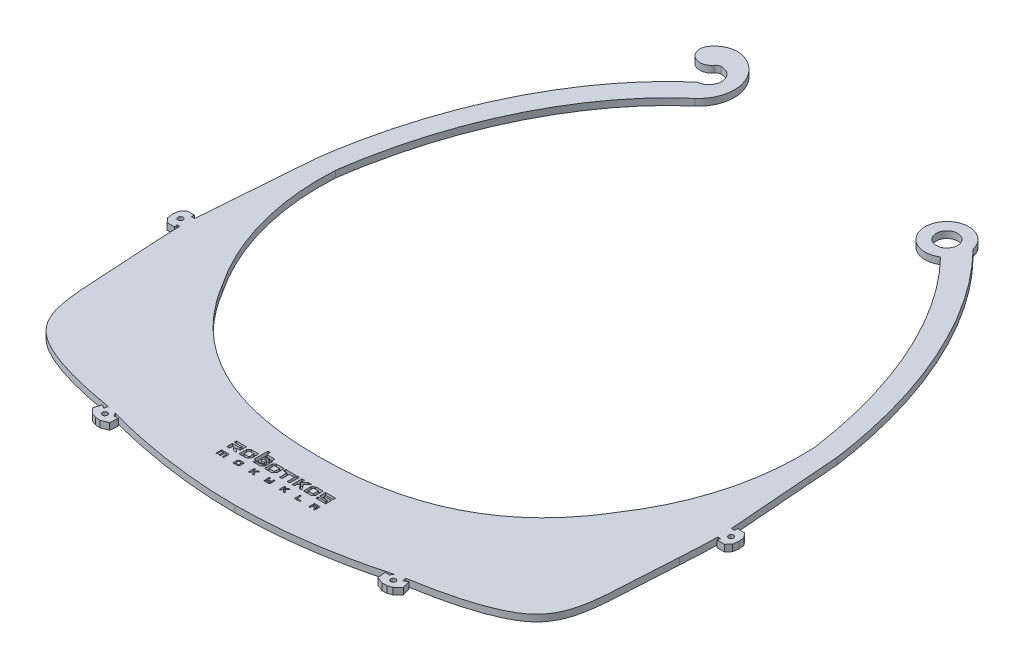
from build123d import *

# Parameters (mm, degrees)
SKETCH2_R           = 0.75
SKETCH2_R_2         = 3.169794379
BOSS_EXTRUDE2_DEPTH = 2
CUT_EXTRUDE1_DEPTH  = 1


with BuildPart() as part:
    # Sketch2 → Boss-Extrude2 (new body)
    with BuildSketch(Plane(origin=(0, 0, 0), x_dir=(1, 0, 0), z_dir=(0, 1, 0))):
        with BuildLine():
            Line((-145.774014845, 4699.790846236), (-145.679424713, 4700.667060475))
            Line((-145.679424713, 4700.667060475), (-147.918372484, 4700.606196913))
            Line((-147.918372484, 4700.606196913), (-149.027988208, 4699.255761252))
            Line((-149.027988208, 4699.255761252), (-149.222790895, 4697.597182293))
            Line((-149.222790895, 4697.597182293), (-148.98298998, 4695.944509376))
            Line((-148.98298998, 4695.944509376), (-147.837087324, 4694.624725063))
            Line((-147.837087324, 4694.624725063), (-145.597312449, 4694.624725063))
            Line((-145.597312449, 4694.624725063), (-145.773758332, 4695.519138342))
            Line((-145.773758332, 4695.519138342), (-144.93974364, 4695.519138342))
            add(Edge.make_bspline(
                [(-144.46397827, 4684.514714632), (-144.606093665, 4687.588466409), (-144.901928293, 4691.324791696), (-144.93974364, 4695.519138342)],
                knots=[0.004734857, 0.004734857, 0.004734857, 0.004734857, 0.035161677, 0.035161677, 0.035161677, 0.035161677], degree=3))
            add(Edge.make_bspline(
                [(-108.903375625, 4638.035656948), (-118.821969125, 4639.685871765), (-132.493488743, 4643.060373116), (-144.218775593, 4654.394416396), (-143.099113193, 4666.334603474), (-144.46397827, 4684.514714632)],
                knots=[0.018902136, 0.018902136, 0.018902136, 0.018902136, 0.394121885, 0.490994555, 0.987628845, 0.987628845, 0.987628845, 0.987628845], degree=3))
            Line((-108.903375625, 4638.035656948), (-109.111012106, 4636.936921529))
            Line((-109.111012106, 4636.936921529), (-110.228421491, 4637.612566847))
            Line((-110.228421491, 4637.612566847), (-110.904437831, 4635.297018365))
            Line((-110.904437831, 4635.297018365), (-109.31209767, 4633.795971308))
            Line((-109.31209767, 4633.795971308), (-107.959504664, 4633.340434244))
            Line((-107.959504664, 4633.340434244), (-106.534299374, 4633.264199495))
            Line((-106.534299374, 4633.264199495), (-104.500152189, 4634.07100473))
            Line((-104.500152189, 4634.07100473), (-104.273152305, 4636.472511323))
            Line((-104.273152305, 4636.472511323), (-105.57754023, 4636.472511323))
            Line((-105.57754023, 4636.472511323), (-106.108269156, 4637.355076027))
            add(Edge.make_bspline(
                [(-64.303390576, 4631.426207785), (-78.229594734, 4631.453371402), (-92.531802759, 4633.559092847), (-106.108269156, 4637.355076027)],
                knots=[0.500293183, 0.500293183, 0.500293183, 0.500293183, 0.981944699, 0.981944699, 0.981944699, 0.981944699], degree=3))
            add(Edge.make_bspline(
                [(-64.303390576, 4631.426207785), (-50.377186419, 4631.453371402), (-36.074978393, 4633.559092847), (-22.498511996, 4637.355076027)],
                knots=[0.500293183, 0.500293183, 0.500293183, 0.500293183, 0.981944699, 0.981944699, 0.981944699, 0.981944699], degree=3))
            Line((-22.498511996, 4637.355076027), (-23.029240922, 4636.472511323))
            Line((-23.029240922, 4636.472511323), (-24.333628848, 4636.472511323))
            Line((-24.333628848, 4636.472511323), (-24.106628964, 4634.07100473))
            Line((-24.106628964, 4634.07100473), (-22.072481779, 4633.264199495))
            Line((-22.072481779, 4633.264199495), (-20.647276489, 4633.340434244))
            Line((-20.647276489, 4633.340434244), (-19.294683483, 4633.795971308))
            Line((-19.294683483, 4633.795971308), (-17.702343322, 4635.297018365))
            Line((-17.702343322, 4635.297018365), (-18.378359662, 4637.612566847))
            Line((-18.378359662, 4637.612566847), (-19.495769046, 4636.936921529))
            Line((-19.495769046, 4636.936921529), (-19.703405528, 4638.035656948))
            add(Edge.make_bspline(
                [(-19.703405528, 4638.035656948), (-9.784812028, 4639.685871765), (3.88670759, 4643.060373116), (15.611994441, 4654.394416396), (14.49233204, 4666.334603474), (15.857197118, 4684.514714632)],
                knots=[0.018902136, 0.018902136, 0.018902136, 0.018902136, 0.394121885, 0.490994555, 0.987628845, 0.987628845, 0.987628845, 0.987628845], degree=3))
            add(Edge.make_bspline(
                [(15.857197118, 4684.514714632), (15.999312513, 4687.588466409), (16.29514714, 4691.324791696), (16.332962487, 4695.519138342)],
                knots=[0.004734857, 0.004734857, 0.004734857, 0.004734857, 0.035161677, 0.035161677, 0.035161677, 0.035161677], degree=3))
            Line((16.332962487, 4695.519138342), (17.166977179, 4695.519138342))
            Line((17.166977179, 4695.519138342), (16.990531296, 4694.624725063))
            Line((16.990531296, 4694.624725063), (19.230306172, 4694.624725063))
            Line((19.230306172, 4694.624725063), (20.376208827, 4695.944509376))
            Line((20.376208827, 4695.944509376), (20.616009742, 4697.597182293))
            Line((20.616009742, 4697.597182293), (20.421207056, 4699.255761252))
            Line((20.421207056, 4699.255761252), (19.311591332, 4700.606196913))
            Line((19.311591332, 4700.606196913), (17.072643561, 4700.667060475))
            Line((17.072643561, 4700.667060475), (17.167233693, 4699.790846236))
            Line((17.167233693, 4699.790846236), (16.143581312, 4699.790846236))
            Line((16.143581312, 4699.790846236), (13.505704616, 4734.046734393))
            add(Edge.make_bspline(
                [(-20.140377949, 4808.505435192), (-19.339215101, 4807.69878822), (-16.169205429, 4804.385156989), (-10.959428961, 4798.073334595), (-4.937431717, 4789.049110006), (0.359464838, 4779.225886251), (4.896611241, 4768.706679247), (8.641256086, 4757.60156043), (11.078840538, 4747.950225277), (12.60715411, 4740.056303981), (13.230863748, 4736.050334581), (13.505704616, 4734.046734393)],
                knots=[-2.547822097, -2.547822097, -2.547822097, -2.547822097, -2.512682102, -2.406957035, -2.301231967, -2.1955069, -2.089781833, -1.984056766, -1.878331699, -1.825469165, -1.772606631, -1.772606631, -1.772606631, -1.772606631], degree=3))
            ThreePointArc((-20.140377949, 4808.505435192), (-32.664266502, 4809.623514522), (-22.989188291, 4801.592901377))
            add(Edge.make_bspline(
                [(7.531205359, 4733.448618243), (1.49518461, 4776.711269913), (-22.989188291, 4801.592901377)],
                knots=[1.775964024, 1.775964024, 1.775964024, 2.543499924, 2.543499924, 2.543499924], degree=2, weights=[1, 0.927260437, 1]))
            ThreePointArc((7.531205359, 4733.448618243), (4.986516441, 4708.998918893), (-5.29304341, 4686.669702846))
            add(Edge.make_bspline(
                [(-64.303390576, 4656.572608608), (-23.423446833, 4656.293379669), (-5.29304341, 4686.669702846)],
                knots=[0, 0, 0, 1, 1, 1], degree=2))
            add(Edge.make_bspline(
                [(-64.303390576, 4656.572608608), (-105.18333432, 4656.293379669), (-123.313737743, 4686.669702846)],
                knots=[0, 0, 0, 1, 1, 1], degree=2))
            ThreePointArc((-123.313737743, 4686.669702846), (-133.593297594, 4708.998918893), (-136.137986511, 4733.448618243))
            add(Edge.make_bspline(
                [(-100.963860647, 4805.950790548), (-129.440493439, 4781.452315035), (-136.137986511, 4733.448618243)],
                knots=[3.66477814, 3.66477814, 3.66477814, 4.507221283, 4.507221283, 4.507221283], degree=2, weights=[1, 0.912590151, 1]))
            ThreePointArc((-100.963860647, 4805.950790548), (-97.422627424, 4815.929347659), (-104.224712723, 4824.043752771))
            ThreePointArc((-104.224712723, 4824.043752771), (-108.705347231, 4824.182862669), (-112.368006092, 4821.59822203))
            ThreePointArc((-112.368006092, 4821.59822203), (-111.611928523, 4816.659274376), (-106.672980869, 4817.415351945))
            ThreePointArc((-106.672980869, 4817.415351945), (-106.103107375, 4817.914471202), (-105.375761358, 4818.126234287))
            ThreePointArc((-105.375761358, 4818.126234287), (-101.312817548, 4814.562168737), (-104.876883098, 4810.499224928))
            add(Edge.make_bspline(
                [(-104.876883098, 4810.499224928), (-106.096560831, 4809.44993496), (-108.458644854, 4807.290890126), (-113.03760026, 4802.595468236), (-118.390037321, 4796.115503959), (-124.190014325, 4787.432936271), (-129.311920423, 4777.946809151), (-133.714255465, 4767.757887709), (-137.358438688, 4756.975851357), (-139.737248923, 4747.587905934), (-141.231816337, 4739.902065904), (-141.842982215, 4735.998688424), (-142.112485768, 4734.046734393)],
                knots=[-2.618407168, -2.618407168, -2.618407168, -2.618407168, -2.5656247, -2.512842233, -2.407277298, -2.301712363, -2.196147428, -2.090582493, -1.985017558, -1.879452622, -1.826670155, -1.773887687, -1.773887687, -1.773887687, -1.773887687], degree=3))
            Line((-142.112485768, 4734.046734393), (-144.750362465, 4699.790846236))
            Line((-144.750362465, 4699.790846236), (-145.774014845, 4699.790846236))
        make_face()
        with Locations((-146.82022248, 4697.629831976)):
            Circle(SKETCH2_R, mode=Mode.SUBTRACT)
        with Locations((-107.515119617, 4635.661753265)):
            Circle(SKETCH2_R, mode=Mode.SUBTRACT)
        with Locations((-21.091661535, 4635.661753265)):
            Circle(SKETCH2_R, mode=Mode.SUBTRACT)
        with Locations((18.213441328, 4697.629831976)):
            Circle(SKETCH2_R, mode=Mode.SUBTRACT)
        with Locations((-26.576401525, 4807.114568719)):
            Circle(SKETCH2_R_2, mode=Mode.SUBTRACT)
    extrude(amount=BOSS_EXTRUDE2_DEPTH)

    # Sketch3 → Cut-Extrude1 (cut)
    with BuildSketch(Plane(origin=(0, 2, 0), x_dir=(1, 0, 0), z_dir=(0, 1, 0))):
        Polygon((-80.67831347, 4642.941212701), (-80.67831347, 4643.793212801), (-79.52631347, 4643.793212801), (-78.37431317, 4643.793212801), (-78.37431317, 4642.941212701), (-78.37431317, 4642.089212901), (-78.57831327, 4642.089212901), (-78.78231337, 4642.089212901), (-78.78231337, 4642.761212701), (-78.78231337, 4643.433212801), (-79.05831317, 4643.433212801), (-79.33431327, 4643.433212801), (-79.33431327, 4642.761212701), (-79.33431327, 4642.089212901), (-79.53831337, 4642.089212901), (-79.74231347, 4642.089212901), (-79.74231347, 4642.761212701), (-79.74231347, 4643.433212801), (-80.00631337, 4643.433212801), (-80.27031327, 4643.433212801), (-80.27031327, 4642.761212701), (-80.27031327, 4642.089212901), (-80.47431337, 4642.089212901), (-80.67831347, 4642.089212901), align=None)
        Polygon((-75.59031337, 4642.755775801), (-75.59031337, 4643.422338801), (-75.40378227, 4643.607775901), (-75.21725127, 4643.793212801), (-74.52778237, 4643.793212801), (-73.83831327, 4643.793212801), (-73.83831327, 4643.114611901), (-73.83831327, 4642.436011401), (-74.01287777, 4642.262612101), (-74.18744177, 4642.089212901), (-74.88887767, 4642.089212901), (-75.59031337, 4642.089212901), align=None)
        Polygon((-74.25831337, 4642.941212701), (-74.25831337, 4643.421212901), (-74.72031327, 4643.427729701), (-75.18231317, 4643.434249401), (-75.18231317, 4642.941212701), (-75.18231317, 4642.448176201), (-74.72031327, 4642.454695901), (-74.25831337, 4642.461212801), align=None, mode=Mode.SUBTRACT)
        with BuildLine():
            Line((-70.93431317, 4642.941212701), (-70.93431317, 4643.793212801))
            Line((-70.93431317, 4643.793212801), (-70.70631327, 4643.793212801))
            Line((-70.70631327, 4643.793212801), (-70.47831307, 4643.793212801))
            Line((-70.47831307, 4643.793212801), (-70.47831307, 4643.427503201))
            Line((-70.47831307, 4643.427503201), (-70.47831307, 4643.061793701))
            Line((-70.47831307, 4643.061793701), (-70.11203147, 4643.427503201))
            Line((-70.11203147, 4643.427503201), (-69.74574987, 4643.793212801))
            Line((-69.74574987, 4643.793212801), (-69.47106907, 4643.793212801))
            Line((-69.47106907, 4643.793212801), (-69.19638817, 4643.793212801))
            Line((-69.19638817, 4643.793212801), (-69.54935057, 4643.437411701))
            add(Edge.make_bspline(
                [(-69.54935057, 4643.437411701), (-69.74347987, 4643.241721401), (-69.90231307, 4643.074049301), (-69.90231307, 4643.064807501)],
                knots=[0, 0, 0, 0, 1, 1, 1, 1], degree=3))
            add(Edge.make_bspline(
                [(-69.90231307, 4643.064807501), (-69.90231307, 4643.055566501), (-69.74010867, 4642.832276101), (-69.54185867, 4642.568608401)],
                knots=[0, 0, 0, 0, 1, 1, 1, 1], degree=3))
            Line((-69.54185867, 4642.568608401), (-69.18140427, 4642.089212901))
            Line((-69.18140427, 4642.089212901), (-69.43985877, 4642.089921501))
            Line((-69.43985877, 4642.089921501), (-69.69831297, 4642.090630201))
            Line((-69.69831297, 4642.090630201), (-69.92631317, 4642.402879501))
            add(Edge.make_bspline(
                [(-69.92631317, 4642.402879501), (-70.05171307, 4642.574616801), (-70.16793917, 4642.733138401), (-70.18459387, 4642.755149901)],
                knots=[0, 0, 0, 0, 1, 1, 1, 1], degree=3))
            add(Edge.make_bspline(
                [(-70.18459387, 4642.755149901), (-70.21166477, 4642.790927701), (-70.23011207, 4642.780092001), (-70.35859377, 4642.652951301)],
                knots=[0, 0, 0, 0, 1, 1, 1, 1], degree=3))
            Line((-70.35859377, 4642.652951301), (-70.50231317, 4642.510731501))
            Line((-70.50231317, 4642.510731501), (-70.50231317, 4642.299980101))
            Line((-70.50231317, 4642.299980101), (-70.50231317, 4642.089229001))
            Line((-70.50231317, 4642.089229001), (-70.71831317, 4642.089229001))
            Line((-70.71831317, 4642.089229001), (-70.93431317, 4642.089229001))
            Line((-70.93431317, 4642.089229001), (-70.93431317, 4642.941212701))
        make_face()
        Polygon((-66.37431307, 4642.281212801), (-66.37431307, 4642.473212701), (-65.70231297, 4642.473212701), (-65.03031287, 4642.473212701), (-65.03031287, 4642.605212801), (-65.03031287, 4642.737212901), (-65.70231297, 4642.737212901), (-66.37431307, 4642.737212901), (-66.37431307, 4643.265212701), (-66.37431307, 4643.793212801), (-66.15831307, 4643.793212801), (-65.94231307, 4643.793212801), (-65.94231307, 4643.445212701), (-65.94231307, 4643.097212901), (-65.48631297, 4643.097212901), (-65.03031287, 4643.097212901), (-65.03031287, 4643.445212701), (-65.03031287, 4643.793212801), (-64.82631307, 4643.793212801), (-64.62231297, 4643.793212801), (-64.62231297, 4643.126649801), (-64.62231297, 4642.460086601), (-64.80884367, 4642.274649701), (-64.99537497, 4642.089212901), (-65.68484387, 4642.089212901), (-66.37431307, 4642.089212901), align=None)
        with BuildLine():
            Line((-61.76631307, 4642.941212701), (-61.76631307, 4643.793212801))
            Line((-61.76631307, 4643.793212801), (-61.53831397, 4643.793212801))
            Line((-61.53831397, 4643.793212801), (-61.31031207, 4643.793212801))
            Line((-61.31031207, 4643.793212801), (-61.31031207, 4643.431095001))
            Line((-61.31031207, 4643.431095001), (-61.31031207, 4643.068977301))
            Line((-61.31031207, 4643.068977301), (-60.93231207, 4643.430671201))
            Line((-60.93231207, 4643.430671201), (-60.55431207, 4643.792365201))
            Line((-60.55431207, 4643.792365201), (-60.29417947, 4643.792790401))
            Line((-60.29417947, 4643.792790401), (-60.03404977, 4643.793215601))
            Line((-60.03404977, 4643.793215601), (-60.37818137, 4643.430185701))
            add(Edge.make_bspline(
                [(-60.37818137, 4643.430185701), (-60.56745347, 4643.230519501), (-60.71943307, 4643.057179501), (-60.71591237, 4643.044985701)],
                knots=[0, 0, 0, 0, 1, 1, 1, 1], degree=3))
            add(Edge.make_bspline(
                [(-60.71591237, 4643.044985701), (-60.71106517, 4643.028196101), (-60.18086737, 4642.310719701), (-60.03178767, 4642.119215601)],
                knots=[0, 0, 0, 0, 1, 1, 1, 1], degree=3))
            add(Edge.make_bspline(
                [(-60.03178767, 4642.119215601), (-60.01341917, 4642.095634201), (-60.06285537, 4642.089215401), (-60.26281417, 4642.089215401)],
                knots=[0, 0, 0, 0, 1, 1, 1, 1], degree=3))
            Line((-60.26281417, 4642.089215401), (-60.51718957, 4642.089215401))
            Line((-60.51718957, 4642.089215401), (-60.76060627, 4642.419215501))
            add(Edge.make_bspline(
                [(-60.76060627, 4642.419215501), (-60.89448657, 4642.600715601), (-61.01153197, 4642.757467301), (-61.02070767, 4642.767552901)],
                knots=[0, 0, 0, 0, 1, 1, 1, 1], degree=3))
            add(Edge.make_bspline(
                [(-61.02070767, 4642.767552901), (-61.02989197, 4642.777638601), (-61.10419647, 4642.725432401), (-61.18585127, 4642.651539101)],
                knots=[0, 0, 0, 0, 1, 1, 1, 1], degree=3))
            Line((-61.18585127, 4642.651539101), (-61.33431307, 4642.517186301))
            Line((-61.33431307, 4642.517186301), (-61.33431307, 4642.303200001))
            Line((-61.33431307, 4642.303200001), (-61.33431307, 4642.089213701))
            Line((-61.33431307, 4642.089213701), (-61.55031307, 4642.089213701))
            Line((-61.55031307, 4642.089213701), (-61.76631307, 4642.089213701))
            Line((-61.76631307, 4642.089213701), (-61.76631307, 4642.941212701))
        make_face()
        Polygon((-57.13431207, 4642.941212701), (-57.13431207, 4643.793212801), (-56.93031397, 4643.793212801), (-56.72631307, 4643.793212801), (-56.72631307, 4643.133212901), (-56.72631307, 4642.473212701), (-56.12631207, 4642.473212701), (-55.52631397, 4642.473212701), (-55.52631397, 4642.281212801), (-55.52631397, 4642.089212901), (-56.33031307, 4642.089212901), (-57.13431207, 4642.089212901), align=None)
        Polygon((-52.83831307, 4642.593212901), (-52.83831307, 4643.097212901), (-52.17831117, 4643.097212901), (-51.51831207, 4643.097212901), (-51.51831207, 4643.241212901), (-51.51831207, 4643.385212901), (-52.17831117, 4643.385212901), (-52.83831307, 4643.385212901), (-52.83831307, 4643.589212701), (-52.83831307, 4643.793212801), (-51.96231117, 4643.793212801), (-51.08631207, 4643.793212801), (-51.08631207, 4642.941212701), (-51.08631207, 4642.089212901), (-51.27831117, 4642.089212901), (-51.47031307, 4642.089212901), (-51.47031307, 4642.413212901), (-51.47031307, 4642.737212901), (-51.93831307, 4642.737212901), (-52.40631307, 4642.737212901), (-52.40631307, 4642.413212901), (-52.40631307, 4642.089212901), (-52.62231307, 4642.089212901), (-52.83831307, 4642.089212901), align=None)
        with BuildLine():
            Line((-80.72631227, 4646.257212901), (-80.72631227, 4647.105212801))
            Line((-80.72631227, 4647.105212801), (-79.57431227, 4647.105212801))
            Line((-79.57431227, 4647.105212801), (-78.42231227, 4647.105212801))
            Line((-78.42231227, 4647.105212801), (-78.42231227, 4647.356980101))
            Line((-78.42231227, 4647.356980101), (-78.42231227, 4647.608747301))
            Line((-78.42231227, 4647.608747301), (-79.56831217, 4647.614980701))
            Line((-79.56831217, 4647.614980701), (-80.71431227, 4647.621214101))
            Line((-80.71431227, 4647.621214101), (-80.72097087, 4647.963214101))
            Line((-80.72097087, 4647.963214101), (-80.72762947, 4648.305214101))
            Line((-80.72762947, 4648.305214101), (-79.23897057, 4648.305214101))
            Line((-79.23897057, 4648.305214101), (-77.75031157, 4648.305214101))
            Line((-77.75031157, 4648.305214101), (-77.75031157, 4647.365421401))
            Line((-77.75031157, 4647.365421401), (-77.75031157, 4646.425628901))
            Line((-77.75031157, 4646.425628901), (-78.28321507, 4646.440524901))
            Line((-78.28321507, 4646.440524901), (-78.81611847, 4646.455421001))
            Line((-78.81611847, 4646.455421001), (-78.27741507, 4645.916318501))
            Line((-78.27741507, 4645.916318501), (-77.73871167, 4645.377215601))
            Line((-77.73871167, 4645.377215601), (-78.20429907, 4645.377215601))
            Line((-78.20429907, 4645.377215601), (-78.66988447, 4645.377215601))
            Line((-78.66988447, 4645.377215601), (-79.20124337, 4645.905212901))
            add(Edge.make_bspline(
                [(-79.20124337, 4645.905212901), (-79.70063397, 4646.401446801), (-79.73791947, 4646.433212701), (-79.82098957, 4646.433212701)],
                knots=[0, 0, 0, 0, 1, 1, 1, 1], degree=3))
            Line((-79.82098957, 4646.433212701), (-79.90937727, 4646.433212701))
            Line((-79.90937727, 4646.433212701), (-79.91584597, 4645.911212701))
            Line((-79.91584597, 4645.911212701), (-79.92231457, 4645.389212701))
            Line((-79.92231457, 4645.389212701), (-80.30774197, 4645.382639101))
            add(Edge.make_bspline(
                [(-80.30774197, 4645.382639101), (-80.51972697, 4645.379025001), (-80.70062697, 4645.383517901), (-80.70974087, 4645.392640101)],
                knots=[0, 0, 0, 0, 1, 1, 1, 1], degree=3))
            add(Edge.make_bspline(
                [(-80.70974087, 4645.392640101), (-80.71885427, 4645.401756301), (-80.72631227, 4645.790812501), (-80.72631227, 4646.257212901)],
                knots=[0, 0, 0, 0, 1, 1, 1, 1], degree=3))
        make_face()
        Polygon((-77.00631317, 4646.475503101), (-77.00631317, 4647.573793601), (-76.64003157, 4647.939503101), (-76.27375027, 4648.305212701), (-75.15203177, 4648.305212701), (-74.03031317, 4648.305212701), (-74.03031317, 4647.218931401), (-74.03031317, 4646.132650101), (-74.40858607, 4645.754931601), (-74.78685907, 4645.377212801), (-75.89658597, 4645.377212801), (-77.00631317, 4645.377212801), align=None)
        Polygon((-74.75031317, 4646.841212601), (-74.75031317, 4647.609212801), (-75.51831337, 4647.609212801), (-76.28631317, 4647.609212801), (-76.28631317, 4646.841212601), (-76.28631317, 4646.073212701), (-75.51831337, 4646.073212701), (-74.75031317, 4646.073212701), align=None, mode=Mode.SUBTRACT)
        Polygon((-69.39831307, 4646.475503101), (-69.39831307, 4647.573793601), (-69.03203147, 4647.939503101), (-68.66574987, 4648.305212701), (-67.54403157, 4648.305212701), (-66.42231297, 4648.305212701), (-66.42231297, 4647.218931401), (-66.42231297, 4646.132650101), (-66.80058587, 4645.754931601), (-67.17885857, 4645.377212801), (-68.28858587, 4645.377212801), (-69.39831307, 4645.377212801), align=None)
        Polygon((-67.14231297, 4646.841212601), (-67.14231297, 4647.609212801), (-67.91031317, 4647.609212801), (-68.67831307, 4647.609212801), (-68.67831307, 4646.841212601), (-68.67831307, 4646.073212701), (-67.91031317, 4646.073212701), (-67.14231297, 4646.073212701), align=None, mode=Mode.SUBTRACT)
        Polygon((-64.86231307, 4646.469212701), (-64.86231307, 4647.561212601), (-65.41431297, 4647.561212601), (-65.96631287, 4647.561212601), (-65.96631287, 4647.933212801), (-65.96631287, 4648.305212701), (-64.47831297, 4648.305212701), (-62.99031277, 4648.305212701), (-62.99031277, 4647.933212801), (-62.99031277, 4647.561212601), (-63.57831297, 4647.561212601), (-64.16631287, 4647.561212601), (-64.16631287, 4646.469212701), (-64.16631287, 4645.377212801), (-64.51431297, 4645.377212801), (-64.86231307, 4645.377212801), align=None)
        Polygon((-62.60631297, 4646.840603401), (-62.60631297, 4648.305212701), (-62.22212687, 4648.305212701), (-61.83794167, 4648.305212701), (-61.84412127, 4646.847212701), (-61.85030077, 4645.389212701), (-62.22830157, 4645.382602301), (-62.60630157, 4645.375991901), align=None)
        with BuildLine():
            Line((-61.09431207, 4646.840579301), (-61.09431207, 4648.305212701))
            Line((-61.09431207, 4648.305212701), (-60.72271837, 4648.305212701))
            Line((-60.72271837, 4648.305212701), (-60.35112187, 4648.305212701))
            Line((-60.35112187, 4648.305212701), (-60.34471557, 4647.691607101))
            Line((-60.34471557, 4647.691607101), (-60.33830927, 4647.078001901))
            Line((-60.33830927, 4647.078001901), (-59.70990797, 4647.692154801))
            Line((-59.70990797, 4647.692154801), (-59.08150677, 4648.306308001))
            Line((-59.08150677, 4648.306308001), (-58.64190707, 4648.299759901))
            Line((-58.64190707, 4648.299759901), (-58.20231017, 4648.293211901))
            Line((-58.20231017, 4648.293211901), (-58.81347397, 4647.674236401))
            add(Edge.make_bspline(
                [(-58.81347397, 4647.674236401), (-59.38789787, 4647.092471301), (-59.42272717, 4647.052200101), (-59.39283867, 4647.004342501)],
                knots=[0, 0, 0, 0, 1, 1, 1, 1], degree=3))
            add(Edge.make_bspline(
                [(-59.39283867, 4647.004342501), (-59.37534897, 4646.976336201), (-59.10302457, 4646.609749001), (-58.78767587, 4646.189701901)],
                knots=[0, 0, 0, 0, 1, 1, 1, 1], degree=3))
            add(Edge.make_bspline(
                [(-58.78767587, 4646.189701901), (-58.47232437, 4645.769654701), (-58.21430927, 4645.415006801), (-58.21430927, 4645.401595601)],
                knots=[0, 0, 0, 0, 1, 1, 1, 1], degree=3))
            add(Edge.make_bspline(
                [(-58.21430927, 4645.401595601), (-58.21430927, 4645.386109901), (-58.35319837, 4645.377211901), (-58.59495677, 4645.377211901)],
                knots=[0, 0, 0, 0, 1, 1, 1, 1], degree=3))
            Line((-58.59495677, 4645.377211901), (-58.97560437, 4645.377211901))
            Line((-58.97560437, 4645.377211901), (-59.42895777, 4645.988569301))
            add(Edge.make_bspline(
                [(-59.42895777, 4645.988569301), (-59.67830167, 4646.324816101), (-59.89026797, 4646.600216101), (-59.89999647, 4646.600569301)],
                knots=[0, 0, 0, 0, 1, 1, 1, 1], degree=3))
            add(Edge.make_bspline(
                [(-59.89999647, 4646.600569301), (-59.90971937, 4646.600909501), (-60.01772217, 4646.506711901), (-60.13999457, 4646.391211701)],
                knots=[0, 0, 0, 0, 1, 1, 1, 1], degree=3))
            Line((-60.13999457, 4646.391211701), (-60.36231017, 4646.181211801))
            Line((-60.36231017, 4646.181211801), (-60.37430077, 4645.785211801))
            Line((-60.37430077, 4645.785211801), (-60.38629127, 4645.389211801))
            Line((-60.38629127, 4645.389211801), (-60.74029037, 4645.382570301))
            Line((-60.74029037, 4645.382570301), (-61.09428937, 4645.375928701))
            Line((-61.09428937, 4645.375928701), (-61.09431207, 4646.840579301))
        make_face()
        Polygon((-57.71031207, 4646.475511301), (-57.71031207, 4647.573801501), (-57.34403047, 4647.939511301), (-56.97774897, 4648.305212701), (-55.85603147, 4648.305212701), (-54.73431397, 4648.305212701), (-54.73431397, 4647.218931401), (-54.73431397, 4646.132650101), (-55.11258607, 4645.754931601), (-55.49085827, 4645.377212801), (-56.60058517, 4645.377212801), (-57.71031207, 4645.377212801), align=None)
        Polygon((-55.45431397, 4646.841212601), (-55.45431397, 4647.609212801), (-56.22231307, 4647.609212801), (-56.99031207, 4647.609212801), (-56.99031207, 4646.841212601), (-56.99031207, 4646.073212701), (-56.22231307, 4646.073212701), (-55.45431397, 4646.073212701), align=None, mode=Mode.SUBTRACT)
        with BuildLine():
            Line((-54.01432817, 4645.717212901), (-54.01432817, 4646.025212801))
            Line((-54.01432817, 4646.025212801), (-52.87432717, 4646.025212801))
            Line((-52.87432717, 4646.025212801), (-51.73432627, 4646.025212801))
            Line((-51.73432627, 4646.025212801), (-51.73432627, 4646.240977801))
            Line((-51.73432627, 4646.240977801), (-51.73432627, 4646.456742801))
            Line((-51.73432627, 4646.456742801), (-52.86832627, 4646.462979001))
            Line((-52.86832627, 4646.462979001), (-54.00232627, 4646.469212401))
            Line((-54.00232627, 4646.469212401), (-54.00861917, 4647.387212401))
            Line((-54.00861917, 4647.387212401), (-54.01491207, 4648.305212401))
            Line((-54.01491207, 4648.305212401), (-52.52662677, 4648.305212401))
            Line((-52.52662677, 4648.305212401), (-51.03834137, 4648.305212401))
            Line((-51.03834137, 4648.305212401), (-51.03834137, 4647.933212501))
            Line((-51.03834137, 4647.933212501), (-51.03834137, 4647.561212301))
            Line((-51.03834137, 4647.561212301), (-52.13034047, 4647.561212301))
            Line((-52.13034047, 4647.561212301), (-53.22233947, 4647.561212301))
            Line((-53.22233947, 4647.561212301), (-53.22233947, 4647.357212501))
            Line((-53.22233947, 4647.357212501), (-53.22233947, 4647.153212401))
            Line((-53.22233947, 4647.153212401), (-52.13034047, 4647.153212401))
            Line((-52.13034047, 4647.153212401), (-51.03834137, 4647.153212401))
            Line((-51.03834137, 4647.153212401), (-51.03834137, 4646.265212301))
            Line((-51.03834137, 4646.265212301), (-51.03834137, 4645.377212501))
            Line((-51.03834137, 4645.377212501), (-52.51033887, 4645.377212501))
            add(Edge.make_bspline(
                [(-52.51033887, 4645.377212501), (-53.31994197, 4645.377212501), (-53.98954197, 4645.384412501), (-53.99834077, 4645.393211201)],
                knots=[0, 0, 0, 0, 1, 1, 1, 1], degree=3))
            add(Edge.make_bspline(
                [(-53.99834077, 4645.393211201), (-54.00712817, 4645.402011701), (-54.01432817, 4645.547812501), (-54.01432817, 4645.717212901)],
                knots=[0, 0, 0, 0, 1, 1, 1, 1], degree=3))
        make_face()
        Polygon((-72.83031327, 4645.833212901), (-72.83031327, 4646.265212601), (-73.10644707, 4646.265212601), (-73.38258127, 4646.265212601), (-73.37644707, 4648.323212701), (-73.37031297, 4650.381212801), (-73.00431287, 4650.387837301), (-72.63831277, 4650.394461901), (-72.63831277, 4649.865837001), (-72.63831277, 4649.337211901), (-71.46231297, 4649.337211901), (-70.28631287, 4649.337211901), (-70.28631287, 4648.833211901), (-70.28631287, 4648.329211901), (-70.09431267, 4648.329211901), (-69.90231277, 4648.329211901), (-69.90231277, 4647.194890201), (-69.90231277, 4646.060569001), (-70.23262327, 4645.730890401), (-70.56293427, 4645.401212001), (-71.69662337, 4645.401212001), (-72.83031297, 4645.401212001), align=None)
        with BuildLine():
            Line((-70.79031317, 4646.469212701), (-70.99325337, 4646.265212601))
            Line((-70.99325337, 4646.265212601), (-71.55178317, 4646.265212601))
            Line((-71.55178317, 4646.265212601), (-72.11031327, 4646.265212601))
            Line((-72.11031327, 4646.265212601), (-72.11031327, 4646.169212801))
            Line((-72.11031327, 4646.169212801), (-72.11031327, 4646.073212701))
            Line((-72.11031327, 4646.073212701), (-71.33031317, 4646.073212701))
            Line((-71.33031317, 4646.073212701), (-70.55031307, 4646.073212701))
            Line((-70.55031307, 4646.073212701), (-70.55031307, 4646.373212601))
            add(Edge.make_bspline(
                [(-70.55031307, 4646.373212601), (-70.55031307, 4646.538212801), (-70.55865257, 4646.673212801), (-70.56884307, 4646.673212801)],
                knots=[0, 0, 0, 0, 1, 1, 1, 1], degree=3))
            add(Edge.make_bspline(
                [(-70.56884307, 4646.673212801), (-70.57903367, 4646.673212801), (-70.67869617, 4646.581412801), (-70.79031317, 4646.469212701)],
                knots=[0, 0, 0, 0, 1, 1, 1, 1], degree=3))
        make_face(mode=Mode.SUBTRACT)
        Polygon((-71.00631317, 4647.321212801), (-71.00631317, 4647.657212701), (-71.55831307, 4647.657212701), (-72.11031327, 4647.657212701), (-72.11031327, 4647.321212801), (-72.11031327, 4646.985212601), (-71.55831307, 4646.985212601), (-71.00631317, 4646.985212601), align=None, mode=Mode.SUBTRACT)
        with BuildLine():
            Line((-71.00631317, 4648.473212801), (-71.00631317, 4648.617212801))
            Line((-71.00631317, 4648.617212801), (-71.58231317, 4648.617212801))
            Line((-71.58231317, 4648.617212801), (-72.15831317, 4648.617212801))
            Line((-72.15831317, 4648.617212801), (-72.15831317, 4648.489212601))
            add(Edge.make_bspline(
                [(-72.15831317, 4648.489212601), (-72.15831317, 4648.418812801), (-72.15111317, 4648.354012801), (-72.14231437, 4648.345212601)],
                knots=[0, 0, 0, 0, 1, 1, 1, 1], degree=3))
            add(Edge.make_bspline(
                [(-72.14231437, 4648.345212601), (-72.13351567, 4648.336413901), (-71.87431447, 4648.329213901), (-71.56631437, 4648.329213901)],
                knots=[0, 0, 0, 0, 1, 1, 1, 1], degree=3))
            Line((-71.56631437, 4648.329213901), (-71.00631457, 4648.329213901))
            Line((-71.00631457, 4648.329213901), (-71.00631317, 4648.473212801))
        make_face(mode=Mode.SUBTRACT)
    extrude(amount=-CUT_EXTRUDE1_DEPTH, mode=Mode.SUBTRACT)


solid = part.part
